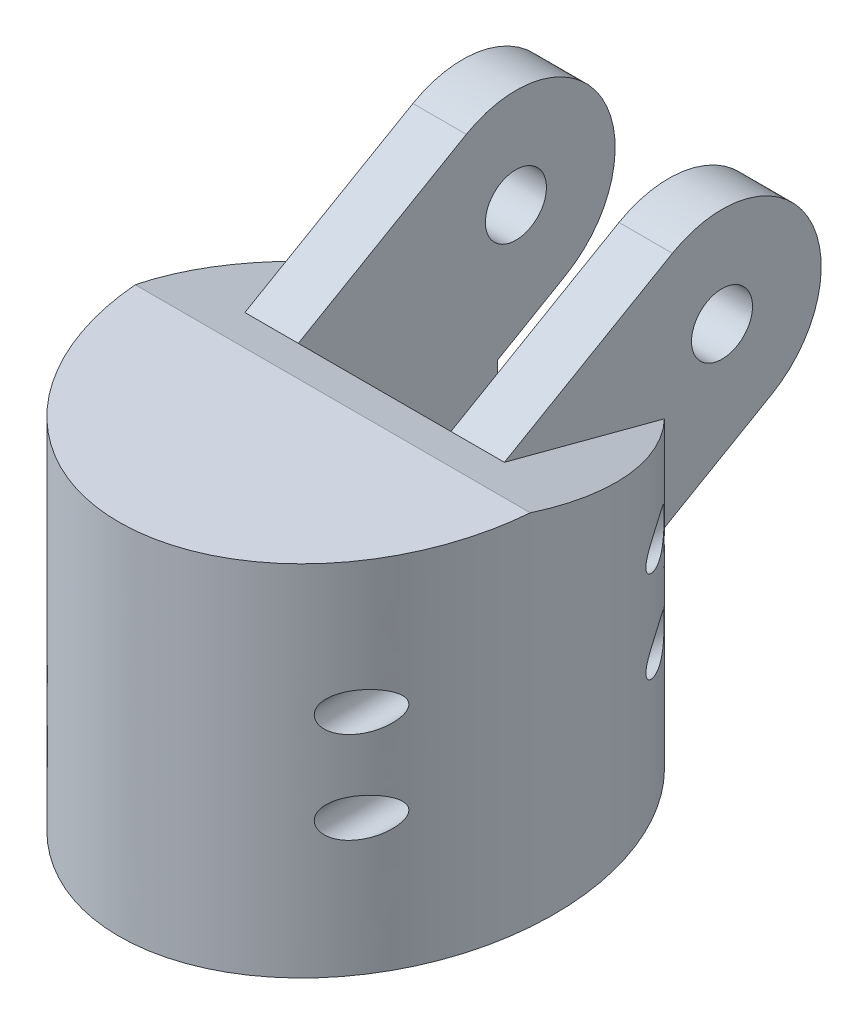
from build123d import *

# Parameters (mm, degrees)
SKETCH2_RX              = 31
SKETCH2_RY              = 26
BOSS_EXTRUDE1_DEPTH     = 47
CUT_EXTRUDE1_DEPTH      = 29
CUT_EXTRUDE2_DEPTH      = 27
CUT_EXTRUDE2_DEPTH_BACK = 27
SKETCH5_R               = 4
BOSS_EXTRUDE2_DEPTH     = 17
SKETCH6_W               = 20
SKETCH6_H               = 38.42056209
CUT_EXTRUDE3_DEPTH      = 61.203194114
SKETCH7_R               = 2.5
CUT_EXTRUDE4_DEPTH      = 32.0000001
CUT_EXTRUDE4_DEPTH_BACK = 45.0000001


with BuildPart() as part:
    # Sketch2 → Boss-Extrude1 (new body)
    with BuildSketch(Plane(origin=(0, 0, 0), x_dir=(1, 0, 0), z_dir=(0, 1, 0))):
        with Locations(Location((0, 0), (0, 0, 90))):
            Ellipse(SKETCH2_RX, SKETCH2_RY)
    extrude(amount=BOSS_EXTRUDE1_DEPTH)

    # Sketch3 → Cut-Extrude1 (cut)
    with BuildSketch(Plane.XZ):
        with BuildLine():
            ThreePointArc((-12.714285714, -5.860626142), (14, 0), (-12.714285714, 5.860626142))
            ThreePointArc((-12.714285714, 5.860626142), (-20, 0), (-12.714285714, -5.860626142))
        make_face()
    extrude(amount=-CUT_EXTRUDE1_DEPTH, mode=Mode.SUBTRACT)

    # Sketch4 → Cut-Extrude2 (cut, two sides)
    with BuildSketch(Plane(origin=(0, 0, 0), x_dir=(0, 0, -1), z_dir=(1, 0, 0))) as cut_extrude2_sk:
        Polygon((-3, 47), (31, 38), (31, 47), align=None)
    extrude(amount=CUT_EXTRUDE2_DEPTH, mode=Mode.SUBTRACT)
    extrude(cut_extrude2_sk.sketch, amount=-CUT_EXTRUDE2_DEPTH_BACK, mode=Mode.SUBTRACT)

    # Sketch5 → Boss-Extrude2 (add, symmetric)
    with BuildSketch(Plane(origin=(0, 0, 0), x_dir=(0, 0, -1), z_dir=(1, 0, 0))):
        with BuildLine():
            Line((2.485147451, 45.548049204), (24.5, 58.258330249))
            ThreePointArc((24.5, 58.258330249), (42.258330249, 53.5), (37.5, 35.741669751))
            Line((37.5, 35.741669751), (15.485147451, 23.031388706))
            Line((15.485147451, 23.031388706), (2.485147451, 45.548049204))
        make_face()
        with Locations((31, 47)):
            Circle(SKETCH5_R, mode=Mode.SUBTRACT)
    extrude(amount=BOSS_EXTRUDE2_DEPTH, both=True)

    # Sketch6 → Cut-Extrude3 (cut, through all)
    with BuildSketch(Plane(origin=(0, 33.084936491, 19.101596989), x_dir=(1, 0, 0), z_dir=(0, 0.866025404, 0.5))):
        with Locations((0, 44.136506472)):
            Rectangle(SKETCH6_W, SKETCH6_H)
    extrude(amount=-CUT_EXTRUDE3_DEPTH, mode=Mode.SUBTRACT)

    # Sketch7 → Cut-Extrude4 (cut, two sides)
    with BuildSketch(Plane.XY) as cut_extrude4_sk:
        with Locations((20, 29.844780472)):
            Circle(SKETCH7_R)
        with Locations((20, 17.844780472)):
            Circle(SKETCH7_R)
    extrude(amount=CUT_EXTRUDE4_DEPTH, mode=Mode.SUBTRACT)
    extrude(cut_extrude4_sk.sketch, amount=-CUT_EXTRUDE4_DEPTH_BACK, mode=Mode.SUBTRACT)


solid = part.part
